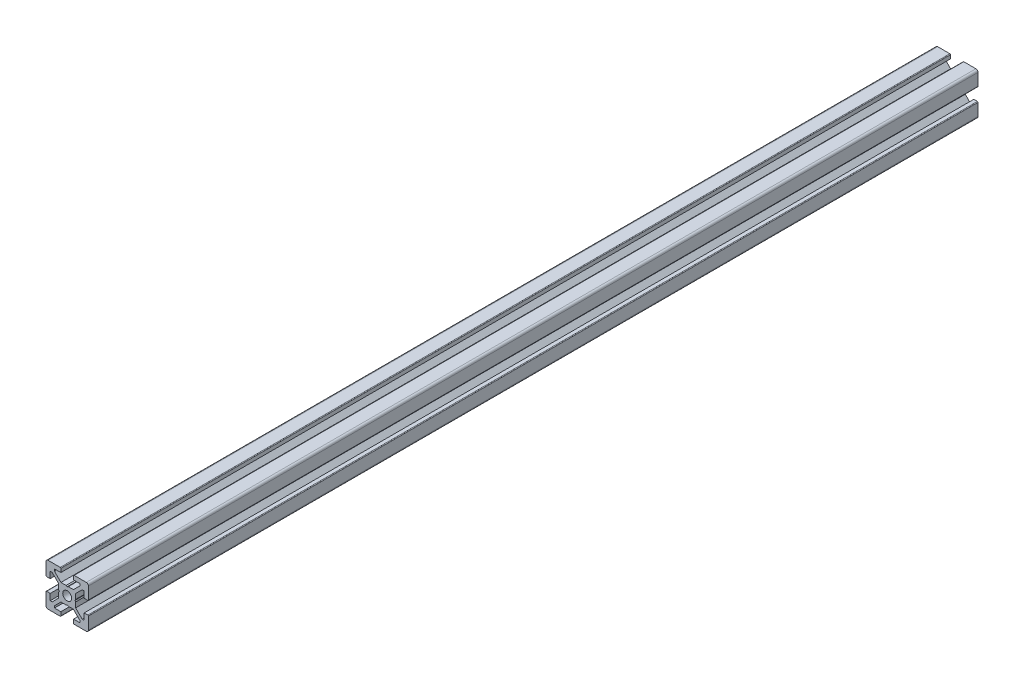
from build123d import *

# Parameters (mm, degrees)
SKETCH1_R           = 2.1
BOSS_EXTRUDE1_DEPTH = 420


with BuildPart() as part:
    # Sketch1 → Boss-Extrude1 (new body)
    with BuildSketch(Plane.XY):
        with BuildLine():
            Line((-10, 9), (-10, 3.29999995))
            ThreePointArc((-10, 3.29999995), (-9.912132049, 3.087867916), (-9.7, 3))
            Line((-9.7, 3), (-8, 3))
            Line((-8, 3), (-8, 6))
            Line((-8, 6), (-7.060677, 6))
            Line((-7.060677, 6), (-4, 2.93932965))
            Line((-4, 2.93932965), (-4, 0.519615242))
            Line((-4, 0.519615242), (-3.699996283, -6.437e-06))
            Line((-3.699996283, -6.437e-06), (-4, -0.519628117))
            Line((-4, -0.519628117), (-4, -2.93933725))
            Line((-4, -2.93933725), (-7.0606695, -6))
            Line((-7.0606695, -6), (-8, -6))
            Line((-8, -6), (-8, -3))
            Line((-8, -3), (-9.7, -3))
            ThreePointArc((-9.7, -3), (-9.912132049, -3.087867916), (-10, -3.29999995))
            Line((-10, -3.29999995), (-10, -9))
            ThreePointArc((-10, -9), (-9.707106781, -9.707106781), (-9, -10))
            Line((-9, -10), (-3.29999995, -10))
            ThreePointArc((-3.29999995, -10), (-3.087867916, -9.912132049), (-3, -9.7))
            Line((-3, -9.7), (-3, -8))
            Line((-3, -8), (-6, -8))
            Line((-6, -8), (-6, -7.0606515))
            Line((-6, -7.0606515), (-2.9393489, -4))
            Line((-2.9393489, -4), (-0.519615242, -4))
            Line((-0.519615242, -4), (6.437e-06, -3.699996283))
            Line((6.437e-06, -3.699996283), (0.519628117, -4))
            Line((0.519628117, -4), (2.9393227, -4))
            Line((2.9393227, -4), (6, -7.060677))
            Line((6, -7.060677), (6, -8))
            Line((6, -8), (3, -8))
            Line((3, -8), (3, -9.7))
            ThreePointArc((3, -9.7), (3.087867916, -9.912132049), (3.29999995, -10))
            Line((3.29999995, -10), (9, -10))
            ThreePointArc((9, -10), (9.707106781, -9.707106781), (10, -9))
            Line((10, -9), (10, -3.29999995))
            ThreePointArc((10, -3.29999995), (9.912132049, -3.087867916), (9.7, -3))
            Line((9.7, -3), (8, -3))
            Line((8, -3), (8, -6))
            Line((8, -6), (7.0606435, -6))
            Line((7.0606435, -6), (4, -2.9393482))
            Line((4, -2.9393482), (4, -0.519615242))
            Line((4, -0.519615242), (3.699996283, 6.437e-06))
            Line((3.699996283, 6.437e-06), (4, 0.519628117))
            Line((4, 0.519628117), (4, 2.9393401))
            Line((4, 2.9393401), (7.060651, 6))
            Line((7.060651, 6), (8, 6))
            Line((8, 6), (8, 3))
            Line((8, 3), (9.7, 3))
            ThreePointArc((9.7, 3), (9.912132049, 3.087867916), (10, 3.29999995))
            Line((10, 3.29999995), (10, 9))
            ThreePointArc((10, 9), (9.707106781, 9.707106781), (9, 10))
            Line((9, 10), (3.29999995, 10))
            ThreePointArc((3.29999995, 10), (3.087867916, 9.912132049), (3, 9.7))
            Line((3, 9.7), (3, 8))
            Line((3, 8), (6, 8))
            Line((6, 8), (6, 7.060669))
            Line((6, 7.060669), (2.9393308, 4))
            Line((2.9393308, 4), (0.519615242, 4))
            Line((0.519615242, 4), (-6.437e-06, 3.699996283))
            Line((-6.437e-06, 3.699996283), (-0.519628117, 4))
            Line((-0.519628117, 4), (-2.93935655, 4))
            Line((-2.93935655, 4), (-6, 7.0606435))
            Line((-6, 7.0606435), (-6, 8))
            Line((-6, 8), (-3, 8))
            Line((-3, 8), (-3, 9.7))
            ThreePointArc((-3, 9.7), (-3.087867966, 9.912132034), (-3.3, 10))
            Line((-3.3, 10), (-9, 10))
            ThreePointArc((-9, 10), (-9.707106781, 9.707106781), (-10, 9))
        make_face()
        Circle(SKETCH1_R, mode=Mode.SUBTRACT)
    extrude(amount=-BOSS_EXTRUDE1_DEPTH)


solid = part.part
